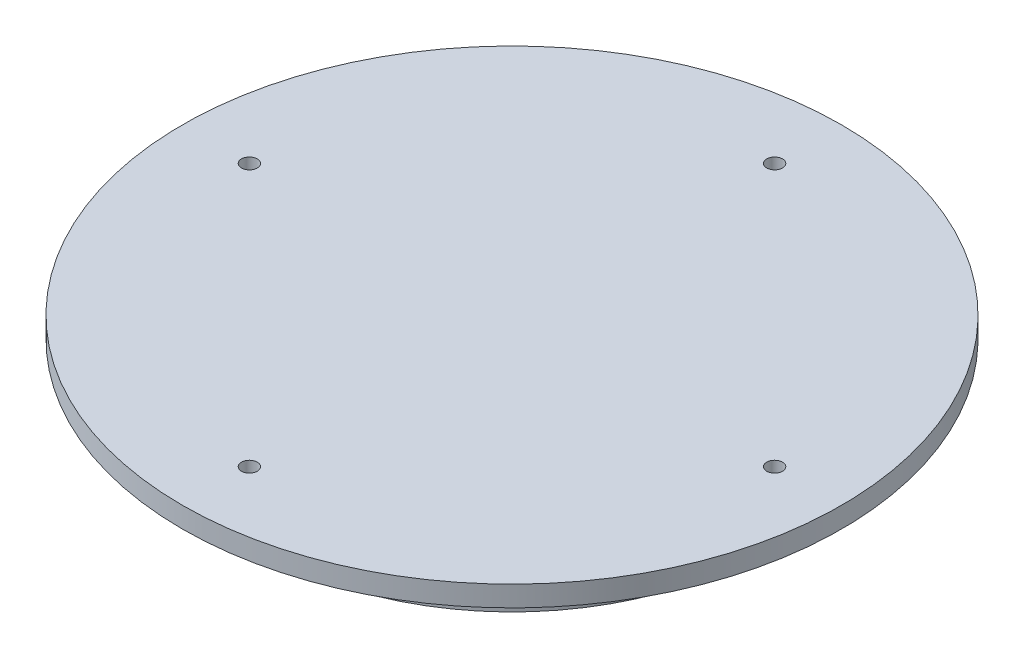
from build123d import *

# Parameters (mm, degrees)
SKETCH1_R                 = 50.8
BOSS_EXTRUDE1_DEPTH       = 3.175
SKETCH2_R                 = 38.1
BOSS_EXTRUDE2_DEPTH       = 9.525
F_2_CLEARANCE_HOLE1_D     = 2.4384
F_2_CLEARANCE_HOLE1_DEPTH = 25.4
F_2_CLEARANCE_HOLE1_TIP   = 0.732569267


with BuildPart() as part:
    # Sketch1 → Boss-Extrude1 (new body)
    with BuildSketch(Plane(origin=(0, 0, 0), x_dir=(1, 0, 0), z_dir=(0, 1, 0))):
        Circle(SKETCH1_R)
    extrude(amount=BOSS_EXTRUDE1_DEPTH)

    # Sketch2 → Boss-Extrude2 (add)
    with BuildSketch(Plane.XZ):
        Circle(SKETCH2_R)
    extrude(amount=BOSS_EXTRUDE2_DEPTH)

    # #2 Clearance Hole1
    with Locations(Plane(origin=(0, 3.175, 0), x_dir=(-1, 0, 0), z_dir=(0, 1, 0))):
        with Locations((0, -40.48125), (-40.48125, 0), (40.48125, 0), (0, 40.48125)):
            Hole(F_2_CLEARANCE_HOLE1_D / 2, depth=F_2_CLEARANCE_HOLE1_DEPTH)
            with Locations((0, 0, -(F_2_CLEARANCE_HOLE1_DEPTH + F_2_CLEARANCE_HOLE1_TIP / 2))):  # 118° drill point
                Cone(0, F_2_CLEARANCE_HOLE1_D / 2, F_2_CLEARANCE_HOLE1_TIP, mode=Mode.SUBTRACT)


solid = part.part
